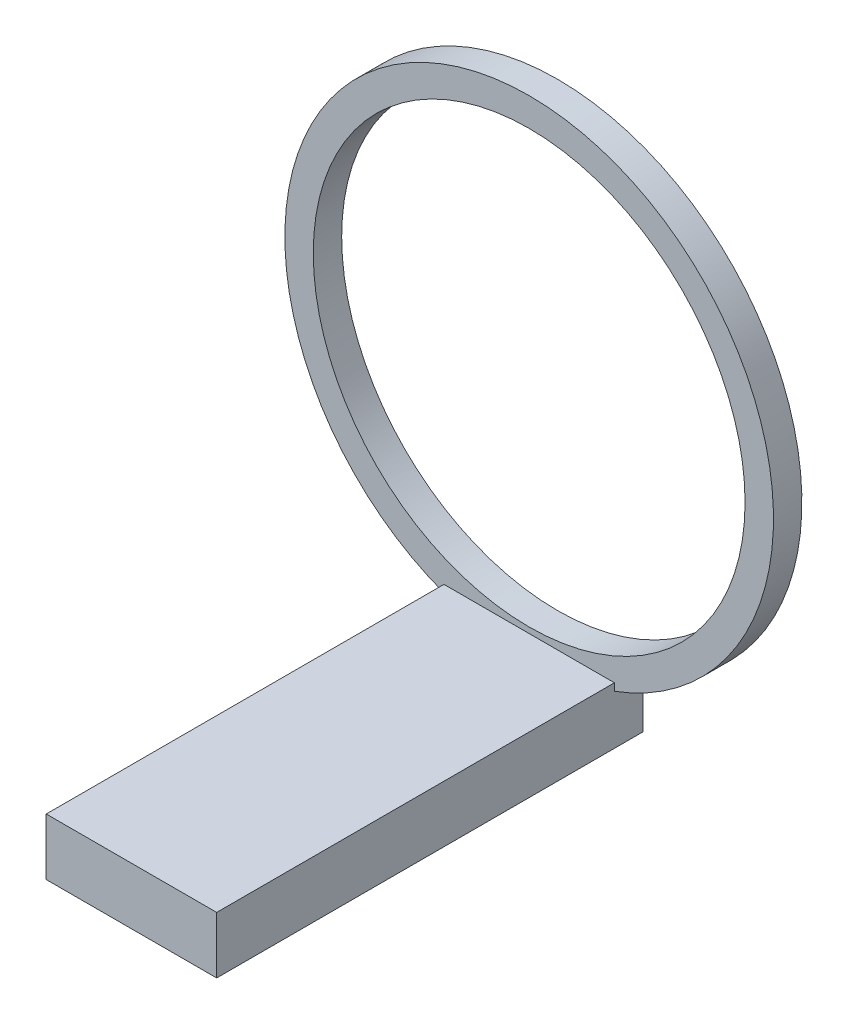
from build123d import *

# Parameters (mm, degrees)
SKETCH1_W           = 38.1
SKETCH1_H           = 12.7
BOSS_EXTRUDE1_DEPTH = 95.25
SKETCH2_R           = 54.61
SKETCH2_R_2         = 48.26
BOSS_EXTRUDE2_DEPTH = 6.35


with BuildPart() as part:
    # Sketch1 → Boss-Extrude1 (new body)
    with BuildSketch(Plane.XY):
        with Locations((0, -6.35)):
            Rectangle(SKETCH1_W, SKETCH1_H)
    extrude(amount=BOSS_EXTRUDE1_DEPTH)

    # Sketch2 → Boss-Extrude2 (add)
    with BuildSketch(Plane(origin=(0, 0, 0), x_dir=(-1, 0, 0), z_dir=(0, 0, -1))):
        with Locations((0, 49.53)):
            Circle(SKETCH2_R)
        with Locations((0, 49.53)):
            Circle(SKETCH2_R_2, mode=Mode.SUBTRACT)
    extrude(amount=-BOSS_EXTRUDE2_DEPTH)


solid = part.part
